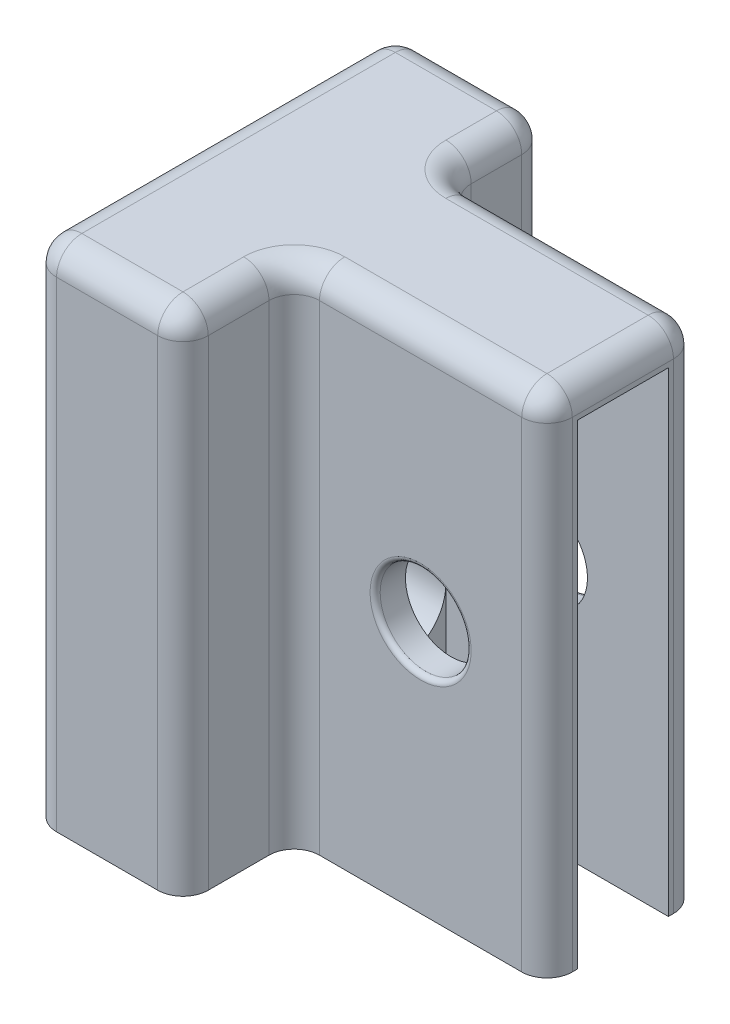
from build123d import *

# Parameters (mm, degrees)
BOSS_EXTRUDE1_DEPTH     = 100
SKETCH2_W               = 30
SKETCH2_H               = 100
BOSS_EXTRUDE3_DEPTH     = 50
SKETCH6_W               = 18
SKETCH6_H               = 94
CUT_EXTRUDE1_DEPTH      = 44
SKETCH7_W               = 18
SKETCH7_H               = 60
CUT_EXTRUDE2_DEPTH      = 94
SKETCH8_R               = 9
CUT_EXTRUDE3_DEPTH      = 1
CUT_EXTRUDE3_DEPTH_BACK = 81
FILLET1_R               = 5
SKETCH9_R               = 9
CUT_EXTRUDE4_DEPTH      = 51
FILLET2_R               = 1


with BuildPart() as part:
    # Sketch1 → Boss-Extrude1 (new body)
    with BuildSketch(Plane(origin=(0, 0, 0), x_dir=(1, 0, 0), z_dir=(0, 1, 0))):
        Polygon((24, 72), (30, 72), (30, 0), (0, 0), (0, 72), (6, 72), align=None)
    extrude(amount=BOSS_EXTRUDE1_DEPTH)

    # Sketch2 → Boss-Extrude3 (add)
    with BuildSketch(Plane(origin=(30, 0, 0), x_dir=(0, 0, -1), z_dir=(1, 0, 0))):
        with Locations((37, 50)):
            Rectangle(SKETCH2_W, SKETCH2_H)
    extrude(amount=BOSS_EXTRUDE3_DEPTH)

    # Sketch6 → Cut-Extrude1 (cut)
    with BuildSketch(Plane(origin=(80, 0, 0), x_dir=(0, 0, -1), z_dir=(1, 0, 0))):
        with Locations((37, 47)):
            Rectangle(SKETCH6_W, SKETCH6_H)
    extrude(amount=-CUT_EXTRUDE1_DEPTH, mode=Mode.SUBTRACT)

    # Sketch7 → Cut-Extrude2 (cut)
    with BuildSketch(Plane.XZ):
        with Locations((15, -36)):
            Rectangle(SKETCH7_W, SKETCH7_H)
    extrude(amount=-CUT_EXTRUDE2_DEPTH, mode=Mode.SUBTRACT)

    # Sketch8 → Cut-Extrude3 (cut, two sides)
    with BuildSketch(Plane.ZY) as cut_extrude3_sk:
        with Locations((-37, 35)):
            Circle(SKETCH8_R)
    extrude(amount=CUT_EXTRUDE3_DEPTH, mode=Mode.SUBTRACT)
    extrude(cut_extrude3_sk.sketch, amount=-CUT_EXTRUDE3_DEPTH_BACK, mode=Mode.SUBTRACT)

    # Fillet1
    fillet1_edges = [part.edges().sort_by_distance(p)[0] for p in [
        (30, 100, -11),
        (0, 50, -72),
        (30, 50, -72),
        (30, 50, 0),
        (0, 50, 0),
        (15, 100, -72),
        (30, 100, -62),
        (30, 50, -22),
        (55, 100, -22),
        (30, 50, -52),
        (55, 100, -52),
        (80, 50, -22),
        (80, 50, -52),
        (80, 100, -37),
        (0, 100, -36),
        (15, 100, 0),
    ]]
    fillet(fillet1_edges, radius=FILLET1_R)

    # Sketch9 → Cut-Extrude4 (cut, through all)
    with BuildSketch(Plane.XY.offset(-22)):
        with Locations((55, 50)):
            Circle(SKETCH9_R)
    extrude(amount=-CUT_EXTRUDE4_DEPTH, mode=Mode.SUBTRACT)

    # Fillet2
    fillet2_edges = [part.edges().sort_by_distance(p)[0] for p in [
        (46, 50, -52),
        (46, 50, -22),
        (0, 35, -46),
    ]]
    fillet(fillet2_edges, radius=FILLET2_R)


solid = part.part
